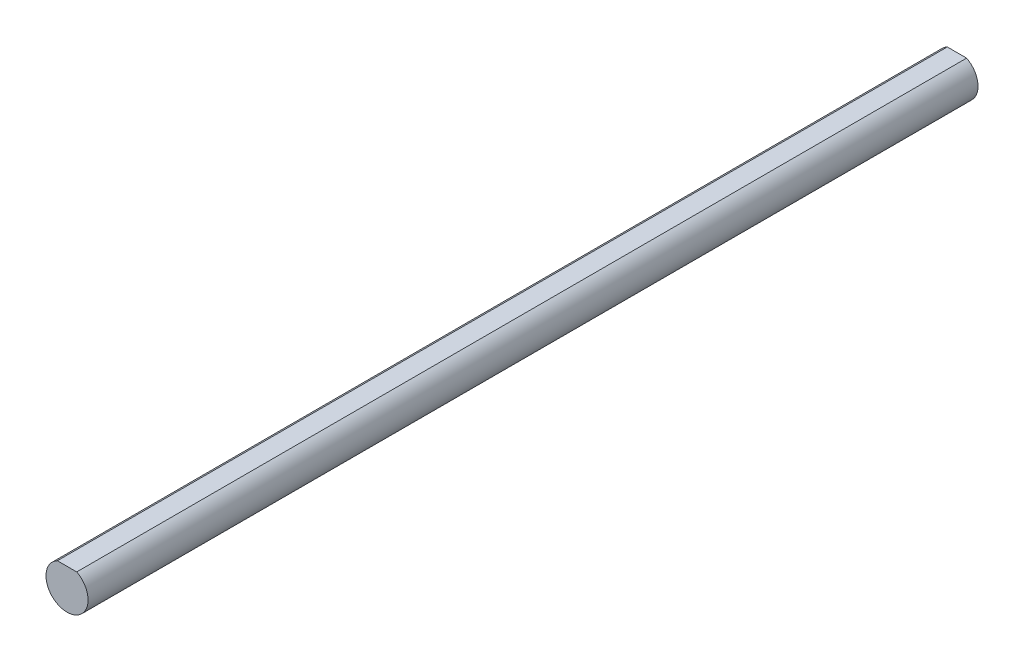
from build123d import *

# Parameters (mm, degrees)
EXTRUDE1_DEPTH = 50


with BuildPart() as part:
    # Sketch1 → Extrude1 (new body, symmetric)
    with BuildSketch(Plane.XY):
        with BuildLine():
            Line((-1.087761463, 2.1), (1.087761463, 2.1))
            ThreePointArc((1.087761463, 2.1), (0, -2.365), (-1.087761463, 2.1))
        make_face()
    extrude(amount=EXTRUDE1_DEPTH, both=True)


solid = part.part
